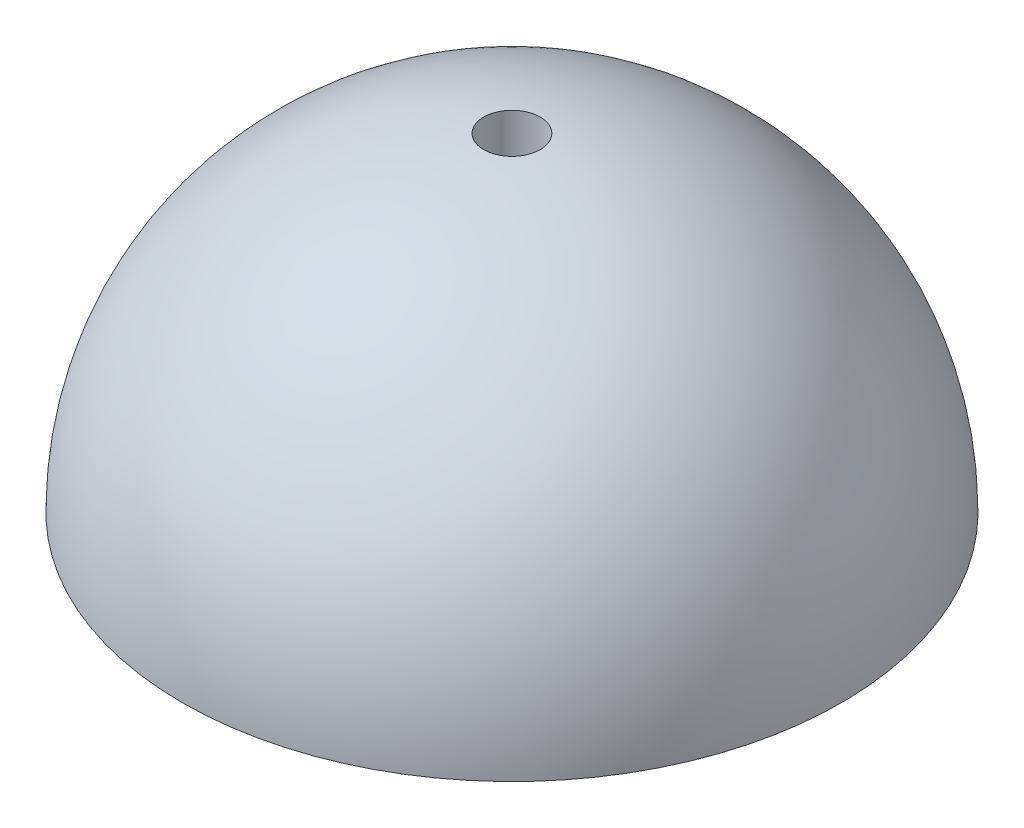
from build123d import *


with BuildPart() as part:
    # Esquisse1 → Révolution1 (revolve)
    with BuildSketch(Plane.XY):
        with BuildLine():
            Line((-17.5, 0), (-1.5, 0))
            Line((-1.5, 0), (-1.5, 17.435595774))
            ThreePointArc((-1.5, 17.435595774), (-12.893796958, 11.832159566), (-17.5, 0))
        make_face()
    revolve(axis=Axis((0, 17.5, 0), (0, -1, 0)))


solid = part.part
